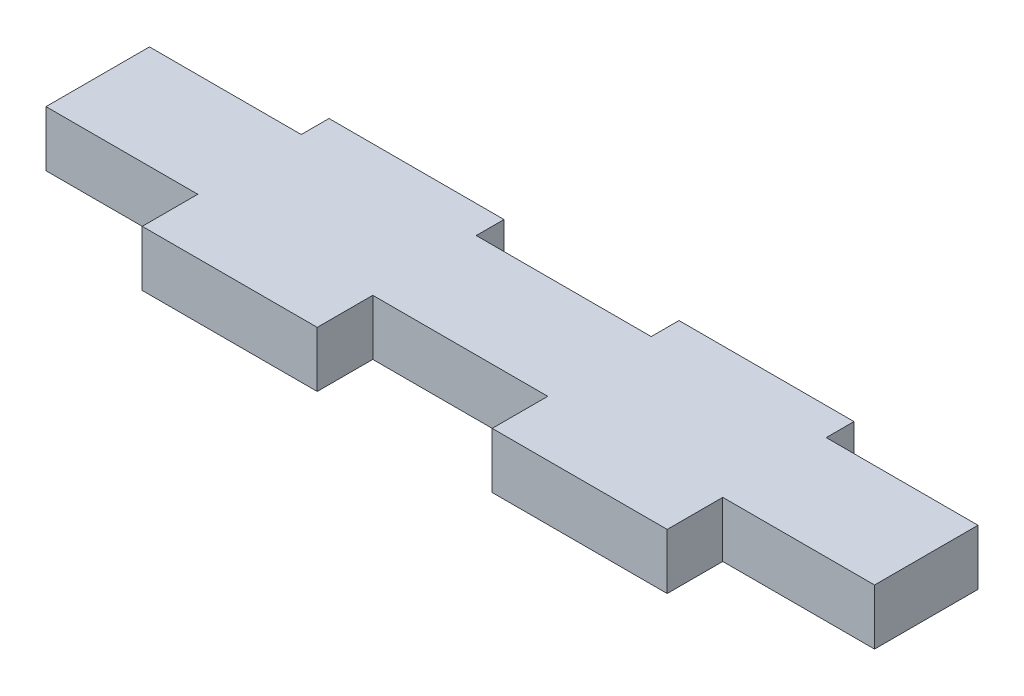
from build123d import *

# Parameters (mm, degrees)
SKETCH1_W           = 47.35
SKETCH1_H           = 10.675
BOSS_EXTRUDE1_DEPTH = 3.175
SKETCH2_W           = 8.675
SKETCH2_H           = 3.175
SKETCH2_W_2         = 10
SKETCH2_H_2         = 1.5875
CUT_EXTRUDE1_DEPTH  = 4.175


with BuildPart() as part:
    # Sketch1 → Boss-Extrude1 (new body)
    with BuildSketch(Plane(origin=(0, 0, 0), x_dir=(1, 0, 0), z_dir=(0, 1, 0))):
        with Locations((23.675, 5.3375)):
            Rectangle(SKETCH1_W, SKETCH1_H)
    extrude(amount=BOSS_EXTRUDE1_DEPTH)

    # Sketch2 → Cut-Extrude1 (cut, through all)
    with BuildSketch(Plane.XZ):
        with Locations((43.0125, -1.5875)):
            Rectangle(SKETCH2_W, SKETCH2_H)
        with Locations((23.675, -1.5875)):
            Rectangle(SKETCH2_W_2, SKETCH2_H)
        with Locations((4.3375, -1.5875)):
            Rectangle(SKETCH2_W, SKETCH2_H)
        with Locations((43.0125, -9.88125)):
            Rectangle(SKETCH2_W, SKETCH2_H_2)
        with Locations((23.675, -9.88125)):
            Rectangle(SKETCH2_W_2, SKETCH2_H_2)
        with Locations((4.3375, -9.88125)):
            Rectangle(SKETCH2_W, SKETCH2_H_2)
    extrude(amount=-CUT_EXTRUDE1_DEPTH, mode=Mode.SUBTRACT)


solid = part.part
